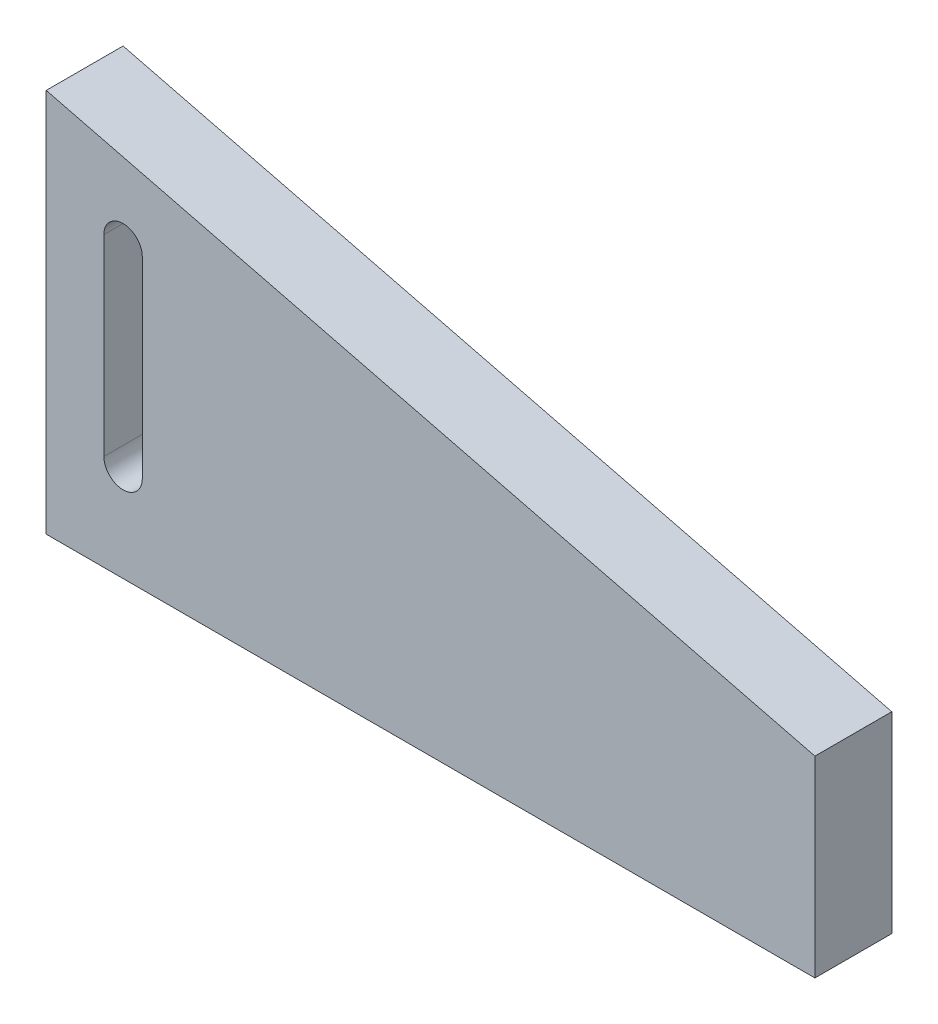
from build123d import *

# Parameters (mm, degrees)
AUFSATZ_LINEAR_AUSTRAGEN1_DEPTH = 10
SCHNITT_LINEAR_AUSTRAGEN1_DEPTH = 21


with BuildPart() as part:
    # Skizze1 → Aufsatz-Linear austragen1 (new body, symmetric)
    with BuildSketch(Plane.XY):
        Polygon((0, 0), (0, 100), (200, 50), (200, 0), align=None)
    extrude(amount=AUFSATZ_LINEAR_AUSTRAGEN1_DEPTH, both=True)

    # Skizze2 → Schnitt-Linear austragen1 (cut, through all)
    with BuildSketch(Plane.XY.offset(10)):
        with BuildLine():
            Line((15, 25), (15, 75))
            ThreePointArc((15, 75), (20, 80), (25, 75))
            Line((25, 75), (25, 25))
            ThreePointArc((25, 25), (20, 20), (15, 25))
        make_face()
    extrude(amount=-SCHNITT_LINEAR_AUSTRAGEN1_DEPTH, mode=Mode.SUBTRACT)


solid = part.part
